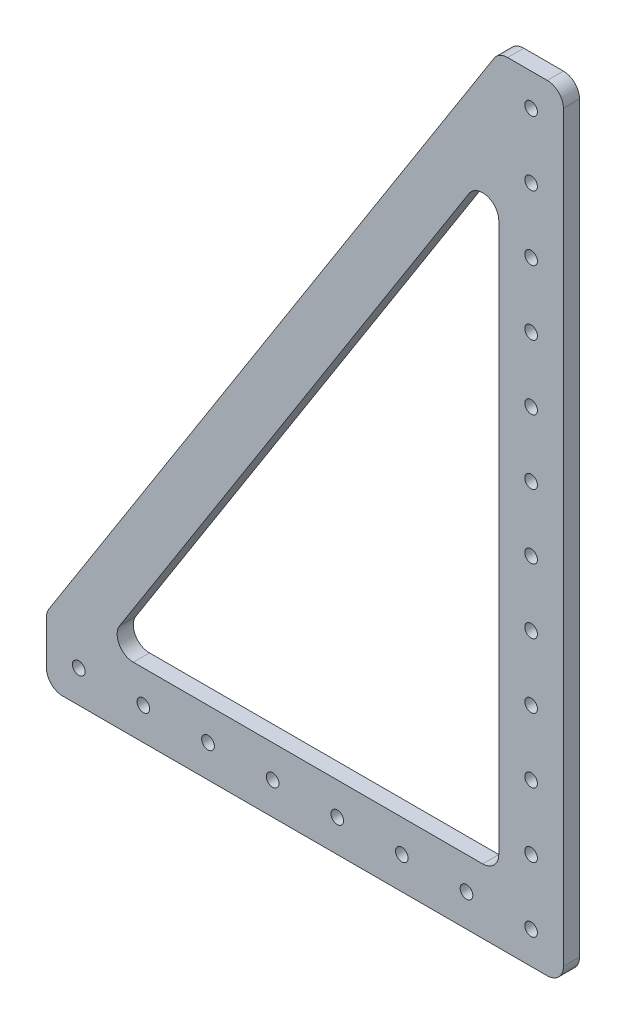
from build123d import *

# Parameters (mm, degrees)
BOSS_EXTRUDE1_DEPTH = 6.35
SKETCH2_R           = 2.4892
CUT_EXTRUDE1_DEPTH  = 7.35
FILLET1_R           = 6.35


with BuildPart() as part:
    # Sketch1 → Boss-Extrude1 (new body)
    with BuildSketch(Plane.XY):
        Polygon((0, 25.4), (177.8, 304.8), (203.2, 304.8), (203.2, 0), (0, 0), align=None)
    extrude(amount=BOSS_EXTRUDE1_DEPTH)

    # Sketch2 → Cut-Extrude1 (cut, through all)
    with BuildSketch(Plane.XY.offset(6.35)):
        with Locations((190.5, 12.7)):
            Circle(SKETCH2_R)
        with Locations((165.1, 12.7)):
            Circle(SKETCH2_R)
        with Locations((139.7, 12.7)):
            Circle(SKETCH2_R)
        with Locations((114.3, 12.7)):
            Circle(SKETCH2_R)
        with Locations((88.9, 12.7)):
            Circle(SKETCH2_R)
        with Locations((63.5, 12.7)):
            Circle(SKETCH2_R)
        with Locations((38.1, 12.7)):
            Circle(SKETCH2_R)
        with Locations((190.5, 38.1)):
            Circle(SKETCH2_R)
        with Locations((190.5, 63.5)):
            Circle(SKETCH2_R)
        with Locations((190.5, 88.9)):
            Circle(SKETCH2_R)
        with Locations((190.5, 114.3)):
            Circle(SKETCH2_R)
        with Locations((190.5, 139.7)):
            Circle(SKETCH2_R)
        with Locations((190.5, 165.1)):
            Circle(SKETCH2_R)
        with Locations((190.5, 190.5)):
            Circle(SKETCH2_R)
        with Locations((190.5, 215.9)):
            Circle(SKETCH2_R)
        with Locations((190.5, 241.3)):
            Circle(SKETCH2_R)
        with Locations((190.5, 266.7)):
            Circle(SKETCH2_R)
        with Locations((190.5, 292.1)):
            Circle(SKETCH2_R)
        with Locations((12.7, 12.7)):
            Circle(SKETCH2_R)
        Polygon((22.580146513, 25.4), (177.8, 25.4), (177.8, 269.316912623), align=None)
    extrude(amount=-CUT_EXTRUDE1_DEPTH, mode=Mode.SUBTRACT)

    # Fillet1
    fillet1_edges = [part.edges().sort_by_distance(p)[0] for p in [
        (22.580146513, 25.4, 3.175),
        (177.8, 269.316912623, 3.175),
        (177.8, 25.4, 3.175),
        (203.2, 0, 3.175),
        (0, 0, 3.175),
        (0, 25.4, 3.175),
        (177.8, 304.8, 3.175),
        (203.2, 304.8, 3.175),
    ]]
    fillet(fillet1_edges, radius=FILLET1_R)


solid = part.part
